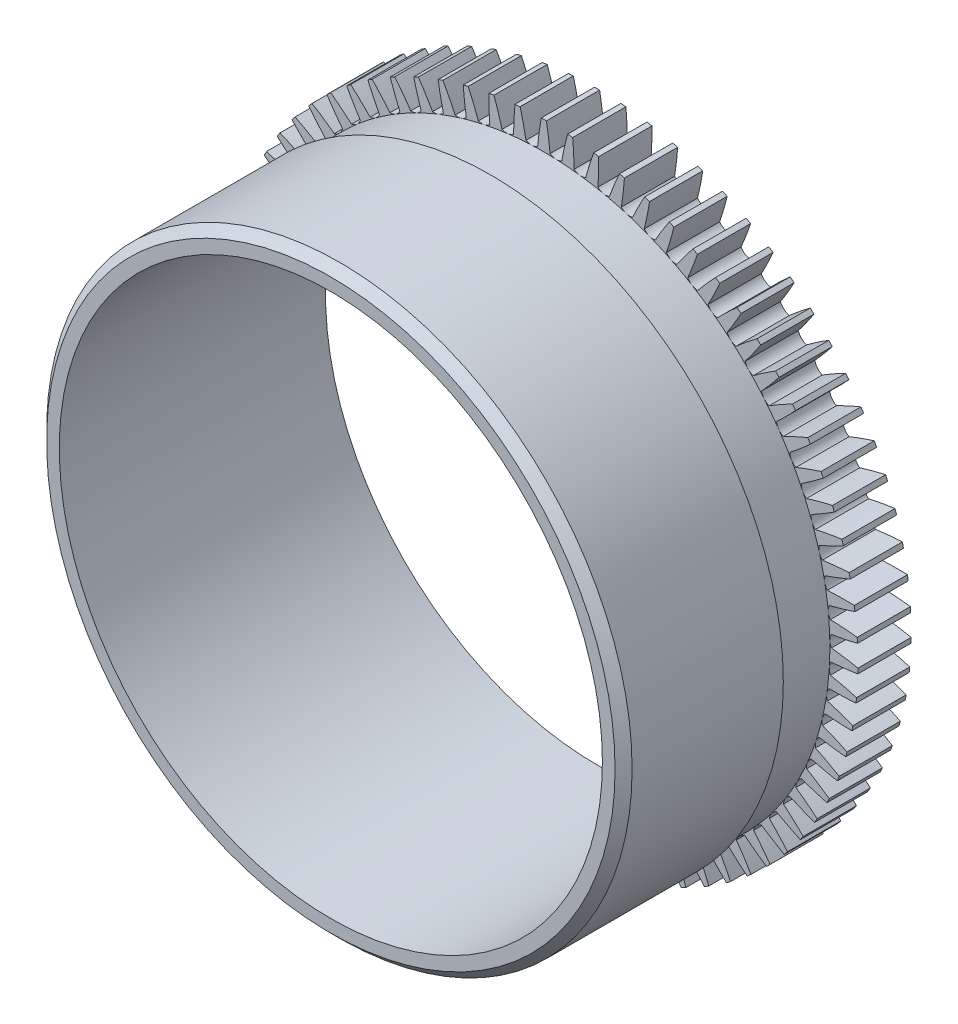
from build123d import *

# Parameters (mm, degrees)
ESQUISSE1_R                  = 29.5
ESQUISSE1_R_2                = 25.5
BOSS_EXTRU_1_DEPTH           = 5
ENL_V_START                  = -1
ENL_V_MAT_EXTRU_1_DEPTH      = 7
R_P_TITION_CIRCULAIRE1_COUNT = 75
ESQUISSE4_R                  = 26.857087404
ESQUISSE4_R_2                = 25.5
BOSS_EXTRU_2_DEPTH           = 5
ESQUISSE5_R                  = 27.49
ESQUISSE5_R_2                = 25.5
BOSS_EXTRU_3_DEPTH           = 15
CHANFREIN1_SIZE              = 0.8


with BuildPart() as part:
    # Esquisse1 → Boss.-Extru.1 (new body)
    with BuildSketch(Plane.XY):
        Circle(ESQUISSE1_R)
        Circle(ESQUISSE1_R_2, mode=Mode.SUBTRACT)
    extrude(amount=BOSS_EXTRU_1_DEPTH)

    # Esquisse3 → Enlèv. mat.-Extru.1 (cut)
    with BuildSketch(Plane(origin=(0, 0, 5), x_dir=(-1, 0, 0), z_dir=(0, 0, -1)).offset(ENL_V_START)):
        with BuildLine():
            Line((1, -31.5), (-1, -31.5))
            Line((-1, -31.5), (-1, -29.5))
            ThreePointArc((-1, -29.5), (-0.748527954, -28.254764968), (-0.55, -27))
            ThreePointArc((-0.55, -27), (0, -26.857087404), (0.55, -27))
            ThreePointArc((0.55, -27), (0.748527954, -28.254764968), (1, -29.5))
            Line((1, -29.5), (1, -31.5))
        make_face()
    enl_v_mat_extru_1 = extrude(amount=ENL_V_MAT_EXTRU_1_DEPTH, mode=Mode.SUBTRACT)

    # Répétition circulaire1: Enlèv. mat.-Extru.1 ×75 about axis
    r_p_tition_circulaire1_axis = Axis((0, 0, 0), (0, 0, 1))
    for i in range(1, R_P_TITION_CIRCULAIRE1_COUNT):
        add(enl_v_mat_extru_1.rotate(r_p_tition_circulaire1_axis, i * 360 / R_P_TITION_CIRCULAIRE1_COUNT), mode=Mode.SUBTRACT)

    # Esquisse4 → Boss.-Extru.2 (add)
    with BuildSketch(Plane.XY.offset(5)):
        Circle(ESQUISSE4_R)
        Circle(ESQUISSE4_R_2, mode=Mode.SUBTRACT)
    extrude(amount=BOSS_EXTRU_2_DEPTH)

    # Esquisse5 → Boss.-Extru.3 (add)
    with BuildSketch(Plane.XY.offset(10)):
        Circle(ESQUISSE5_R)
        Circle(ESQUISSE5_R_2, mode=Mode.SUBTRACT)
    extrude(amount=BOSS_EXTRU_3_DEPTH)

    # Chanfrein1
    chanfrein1_edges = [part.edges().sort_by_distance(p)[0] for p in [
        (-27.49, 0, 25),
    ]]
    chamfer(chanfrein1_edges, length=CHANFREIN1_SIZE)


solid = part.part
